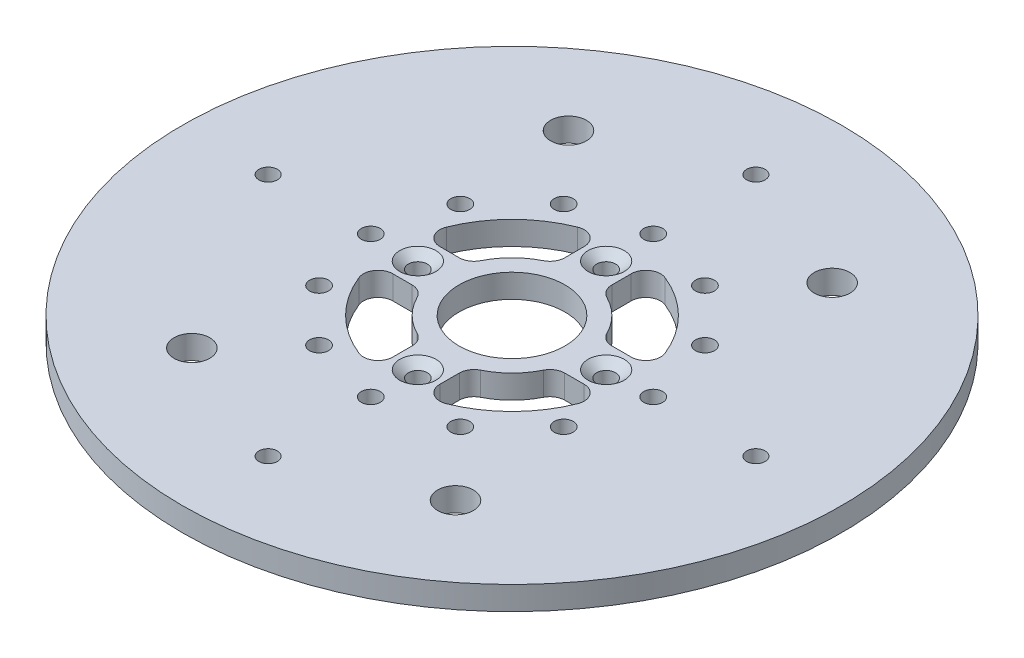
from build123d import *

# Parameters (mm, degrees)
SKETCH1_R                                          = 88.9
BOSS_EXTRUDE1_DEPTH                                = 6.35
SKETCH2_R                                          = 14.2875
CUT_EXTRUDE1_DEPTH                                 = 7.35
CSK_FOR_10_FLAT_HEAD_MACHINE_SCREW_100_D           = 5.1054
CSK_FOR_10_FLAT_HEAD_MACHINE_SCREW_100_CSINK_D     = 9.779
CSK_FOR_10_FLAT_HEAD_MACHINE_SCREW_100_CSINK_ANGLE = 100
F_9_0_196_DIAMETER_HOLE1_D                         = 4.9784
F_1_4_20_TAPPED_HOLE1_D                            = 5.1054
CUT_EXTRUDE3_DEPTH                                 = 6.35
SKETCH17_R                                         = 4.826
CUT_EXTRUDE4_DEPTH                                 = 7.35


with BuildPart() as part:
    # Sketch1 → Boss-Extrude1 (new body)
    with BuildSketch(Plane(origin=(0, 0, 0), x_dir=(1, 0, 0), z_dir=(0, 1, 0))):
        Circle(SKETCH1_R)
    extrude(amount=BOSS_EXTRUDE1_DEPTH)

    # Sketch2 → Cut-Extrude1 (cut, through all)
    with BuildSketch(Plane(origin=(0, 6.35, 0), x_dir=(1, 0, 0), z_dir=(0, 1, 0))):
        Circle(SKETCH2_R)
    extrude(amount=-CUT_EXTRUDE1_DEPTH, mode=Mode.SUBTRACT)

    # CSK for #10 Flat Head Machine Screw (100)1 (through all)
    with Locations(Plane(origin=(0, 6.35, 0), x_dir=(1, 0, 0), z_dir=(0, 1, 0))):
        with Locations((0, 25.4), (25.4, 0), (0, -25.4), (-25.4, 0)):
            CounterSinkHole(CSK_FOR_10_FLAT_HEAD_MACHINE_SCREW_100_D / 2, CSK_FOR_10_FLAT_HEAD_MACHINE_SCREW_100_CSINK_D / 2, counter_sink_angle=CSK_FOR_10_FLAT_HEAD_MACHINE_SCREW_100_CSINK_ANGLE)

    # #9 (0.196) Diameter Hole1 (through all)
    with Locations(Plane(origin=(0, 6.35, 0), x_dir=(1, 0, 0), z_dir=(0, 1, 0))):
        with Locations((0, 65.786), (65.786, 0), (0, -65.786), (-65.786, 0)):
            Hole(F_9_0_196_DIAMETER_HOLE1_D / 2)

    # 1/4-20 Tapped Hole1 (through all)
    with Locations(Plane(origin=(0, 6.35, 0), x_dir=(1, 0, 0), z_dir=(0, 1, 0))):
        with Locations((0, 38.1), (19.05, 32.995567884), (32.995567884, 19.05), (38.1, 0), (32.995567884, -19.05), (19.05, -32.995567884), (0, -38.1), (-19.05, -32.995567884), (-32.995567884, -19.05), (-38.1, 0), (-32.995567884, 19.05), (-19.05, 32.995567884)):
            Hole(F_1_4_20_TAPPED_HOLE1_D / 2)

    # Sketch16 → Cut-Extrude3 (cut)
    with BuildSketch(Plane(origin=(0, 6.35, 0), x_dir=(1, 0, 0), z_dir=(0, 1, 0))):
        with BuildLine():
            Line((20.576351717, 6.35), (25.793821935, 6.35))
            ThreePointArc((25.793821935, 6.35), (29.080259161, 8.09382148), (29.47865364, 11.792857143))
            ThreePointArc((29.47865364, 11.792857143), (22.450640303, 22.450640303), (11.792857143, 29.47865364))
            ThreePointArc((11.792857143, 29.47865364), (8.09382148, 29.080259161), (6.35, 25.793821935))
            Line((6.35, 25.793821935), (6.35, 20.576351717))
            ThreePointArc((6.35, 20.576351717), (6.941490818, 18.491862096), (8.539655172, 17.02870487))
            ThreePointArc((8.539655172, 17.02870487), (13.470384182, 13.470384182), (17.02870487, 8.539655172))
            ThreePointArc((17.02870487, 8.539655172), (18.491862096, 6.941490818), (20.576351717, 6.35))
        make_face()
        with BuildLine():
            Line((6.35, -20.576351717), (6.35, -25.793821935))
            ThreePointArc((6.35, -25.793821935), (8.09382148, -29.080259161), (11.792857143, -29.47865364))
            ThreePointArc((11.792857143, -29.47865364), (22.450640303, -22.450640303), (29.47865364, -11.792857143))
            ThreePointArc((29.47865364, -11.792857143), (29.080259161, -8.09382148), (25.793821935, -6.35))
            Line((25.793821935, -6.35), (20.576351717, -6.35))
            ThreePointArc((20.576351717, -6.35), (18.491862096, -6.941490818), (17.02870487, -8.539655172))
            ThreePointArc((17.02870487, -8.539655172), (13.470384182, -13.470384182), (8.539655172, -17.02870487))
            ThreePointArc((8.539655172, -17.02870487), (6.941490818, -18.491862096), (6.35, -20.576351717))
        make_face()
        with BuildLine():
            Line((-20.576351717, -6.35), (-25.793821935, -6.35))
            ThreePointArc((-25.793821935, -6.35), (-29.080259161, -8.09382148), (-29.47865364, -11.792857143))
            ThreePointArc((-29.47865364, -11.792857143), (-22.450640303, -22.450640303), (-11.792857143, -29.47865364))
            ThreePointArc((-11.792857143, -29.47865364), (-8.09382148, -29.080259161), (-6.35, -25.793821935))
            Line((-6.35, -25.793821935), (-6.35, -20.576351717))
            ThreePointArc((-6.35, -20.576351717), (-6.941490818, -18.491862096), (-8.539655172, -17.02870487))
            ThreePointArc((-8.539655172, -17.02870487), (-13.470384182, -13.470384182), (-17.02870487, -8.539655172))
            ThreePointArc((-17.02870487, -8.539655172), (-18.491862096, -6.941490818), (-20.576351717, -6.35))
        make_face()
        with BuildLine():
            Line((-6.35, 20.576351717), (-6.35, 25.793821935))
            ThreePointArc((-6.35, 25.793821935), (-8.09382148, 29.080259161), (-11.792857143, 29.47865364))
            ThreePointArc((-11.792857143, 29.47865364), (-22.450640303, 22.450640303), (-29.47865364, 11.792857143))
            ThreePointArc((-29.47865364, 11.792857143), (-29.080259161, 8.09382148), (-25.793821935, 6.35))
            Line((-25.793821935, 6.35), (-20.576351717, 6.35))
            ThreePointArc((-20.576351717, 6.35), (-18.491862096, 6.941490818), (-17.02870487, 8.539655172))
            ThreePointArc((-17.02870487, 8.539655172), (-13.470384182, 13.470384182), (-8.539655172, 17.02870487))
            ThreePointArc((-8.539655172, 17.02870487), (-6.941490818, 18.491862096), (-6.35, 20.576351717))
        make_face()
    extrude(amount=-CUT_EXTRUDE3_DEPTH, mode=Mode.SUBTRACT)

    # Sketch17 → Cut-Extrude4 (cut, through all)
    with BuildSketch(Plane(origin=(0, 6.35, 0), x_dir=(1, 0, 0), z_dir=(0, 1, 0))):
        with Locations((-35.56, -50.8)):
            Circle(SKETCH17_R)
        with Locations((-35.56, 50.8)):
            Circle(SKETCH17_R)
        with Locations((35.56, -50.8)):
            Circle(SKETCH17_R)
        with Locations((35.56, 50.8)):
            Circle(SKETCH17_R)
    extrude(amount=-CUT_EXTRUDE4_DEPTH, mode=Mode.SUBTRACT)


solid = part.part
